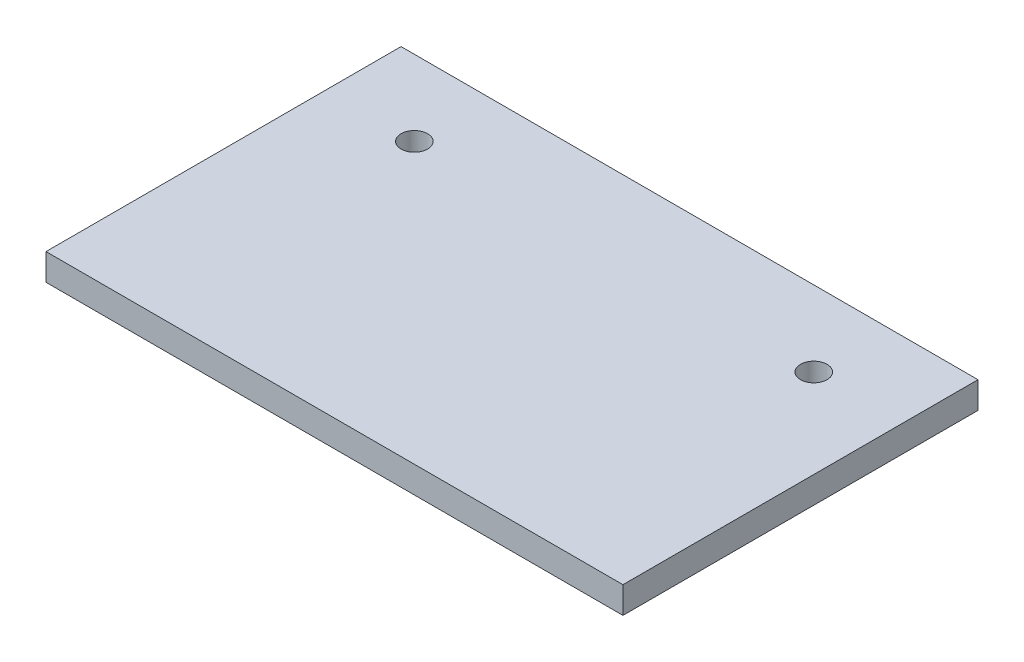
from build123d import *

# Parameters (mm, degrees)
SKETCH_1_W          = 65
SKETCH_1_H          = 40
EXTRUDE_1_DEPTH     = 3
SKETCH_2_R          = 1.5
CUT_EXTRUDE_1_DEPTH = 3


with BuildPart() as part:
    # 草图1 → 凸台-拉伸1 (new body)
    with BuildSketch(Plane(origin=(0, 0, 0), x_dir=(1, 0, 0), z_dir=(0, 1, 0))):
        with Locations((32.5, -20)):
            Rectangle(SKETCH_1_W, SKETCH_1_H)
    extrude(amount=EXTRUDE_1_DEPTH)

    # 草图2 → 切除-拉伸1 (cut)
    with BuildSketch(Plane(origin=(0, 3, 0), x_dir=(1, 0, 0), z_dir=(0, 1, 0))):
        with Locations((10, -8.5)):
            Circle(SKETCH_2_R)
        with Locations((55, -8.5)):
            Circle(SKETCH_2_R)
    extrude(amount=-CUT_EXTRUDE_1_DEPTH, mode=Mode.SUBTRACT)


solid = part.part
